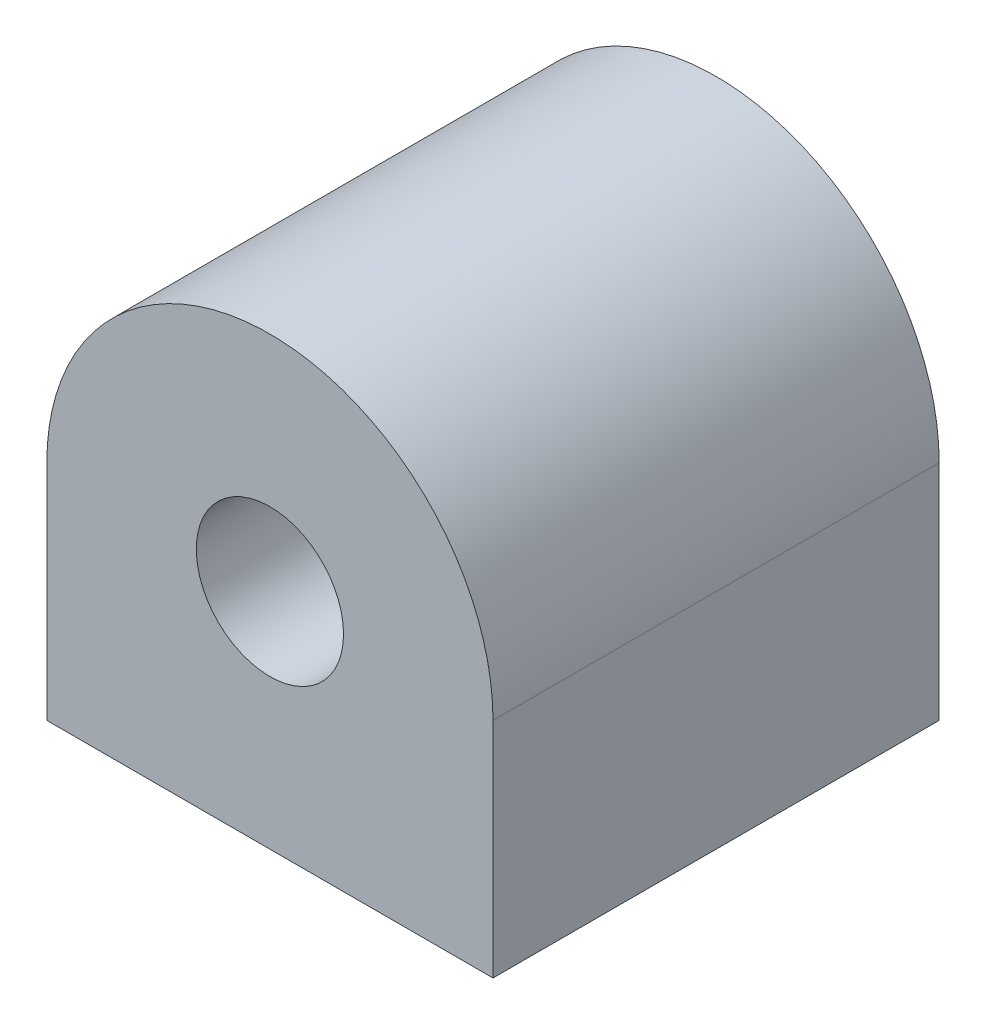
from build123d import *

# Parameters (mm, degrees)
SKETCH1_R           = 1.65
BOSS_EXTRUDE1_DEPTH = 10


with BuildPart() as part:
    # Sketch1 → Boss-Extrude1 (new body)
    with BuildSketch(Plane.XY):
        with BuildLine():
            Line((5, 0), (5, -5))
            Line((5, -5), (-5, -5))
            Line((-5, -5), (-5, 0))
            ThreePointArc((-5, 0), (0, 5), (5, 0))
        make_face()
        Circle(SKETCH1_R, mode=Mode.SUBTRACT)
    extrude(amount=BOSS_EXTRUDE1_DEPTH)


solid = part.part
